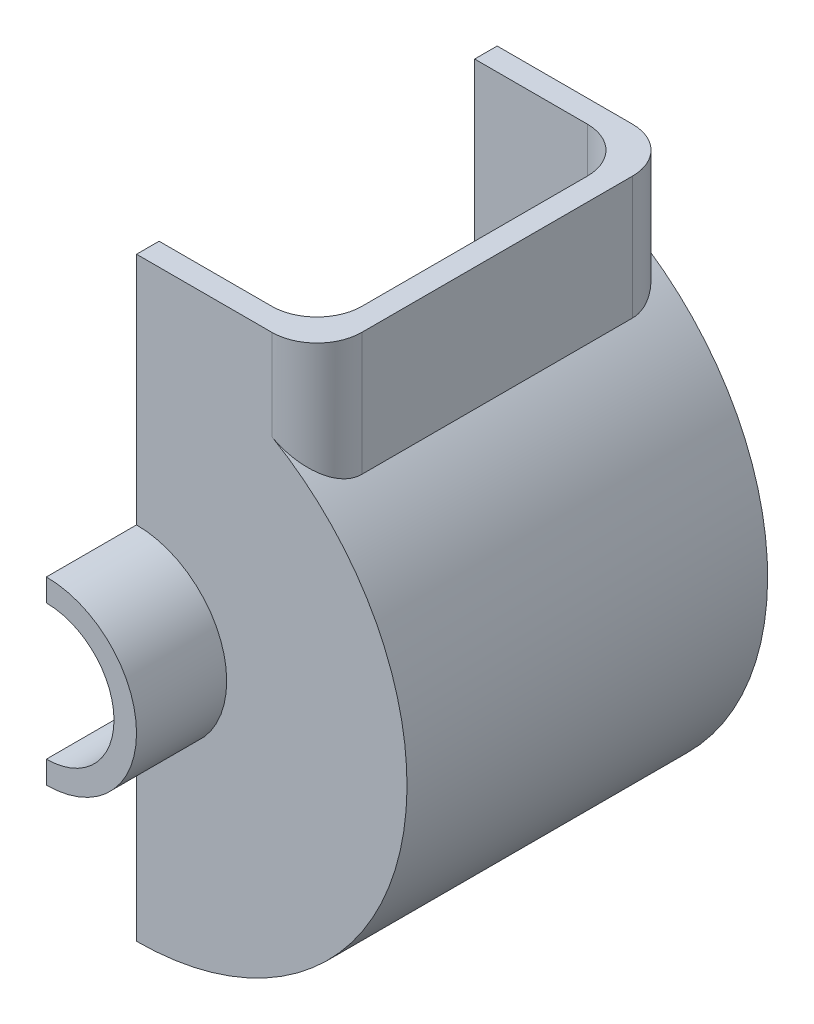
from build123d import *

# Parameters (mm, degrees)
BOSS_EXTRUDE1_DEPTH = 25
BOSS_EXTRUDE3_DEPTH = 5
EXTRUDE_THIN2_START = -70
EXTRUDE_THIN2_DEPTH = 70
FILLET1_R           = 10


with BuildPart() as part:
    # Sketch1 → Boss-Extrude1 (new body)
    with BuildSketch(Plane.XY):
        with BuildLine():
            Line((0, -20), (0, -15))
            ThreePointArc((0, -15), (15, 0), (0, 15))
            Line((0, 15), (0, 20))
            ThreePointArc((0, 20), (20, 0), (0, -20))
        make_face()
    extrude(amount=BOSS_EXTRUDE1_DEPTH)


with BuildPart() as body_2:
    # Sketch3 → Boss-Extrude3 (new body)
    with BuildSketch(Plane.XY):
        with BuildLine():
            Line((0, -20), (0, -60))
            ThreePointArc((0, -60), (56.050341538, -21.409325386), (40, 44.72135955))
            Line((40, 44.72135955), (40, 72))
            Line((40, 72), (0, 72))
            Line((0, 72), (0, 60))
            Line((0, 60), (0, 20))
            ThreePointArc((0, 20), (20, 0), (0, -20))
        make_face()
    extrude(amount=BOSS_EXTRUDE3_DEPTH)


with BuildPart() as body_3:
    # Mirror5: mirrored copy
    add(part.part.mirror(Plane.XY.offset(-35)))


with BuildPart() as body_4:
    # Mirror5 2: mirrored copy
    add(body_2.part.mirror(Plane.XY.offset(-35)))


with BuildPart() as part_1:
    add(part.part)

    add(body_2.part)  # Extrude-Thin2 merges body 2

    add(body_4.part)  # Extrude-Thin2 merges body 4

    add(body_3.part)  # Extrude-Thin2 merges body 3
    # Sketch5 → Extrude-Thin2 (add)
    with BuildSketch(Plane.XY.offset(EXTRUDE_THIN2_START)):
        with BuildLine():
            ThreePointArc((0, -60), (56.050341538, -21.409325386), (40, 44.72135955))
            Line((40, 44.72135955), (40, 72))
            Line((40, 72), (35, 72))
            Line((35, 72), (35, 42.426406871))
            ThreePointArc((35, 42.426406871), (51.76124215, -18.594994247), (0, -55))
            Line((0, -55), (0, -60))
        make_face()
    extrude(amount=EXTRUDE_THIN2_DEPTH)

    # Fillet1
    fillet1_edges = [part_1.edges().sort_by_distance(p)[0] for p in [
        (40, 58.360679775, 5),
        (35, 57.213203436, -70),
        (35, 57.213203436, 0),
        (40, 58.360679775, -75),
    ]]
    fillet(fillet1_edges, radius=FILLET1_R)


solid = part_1.part
